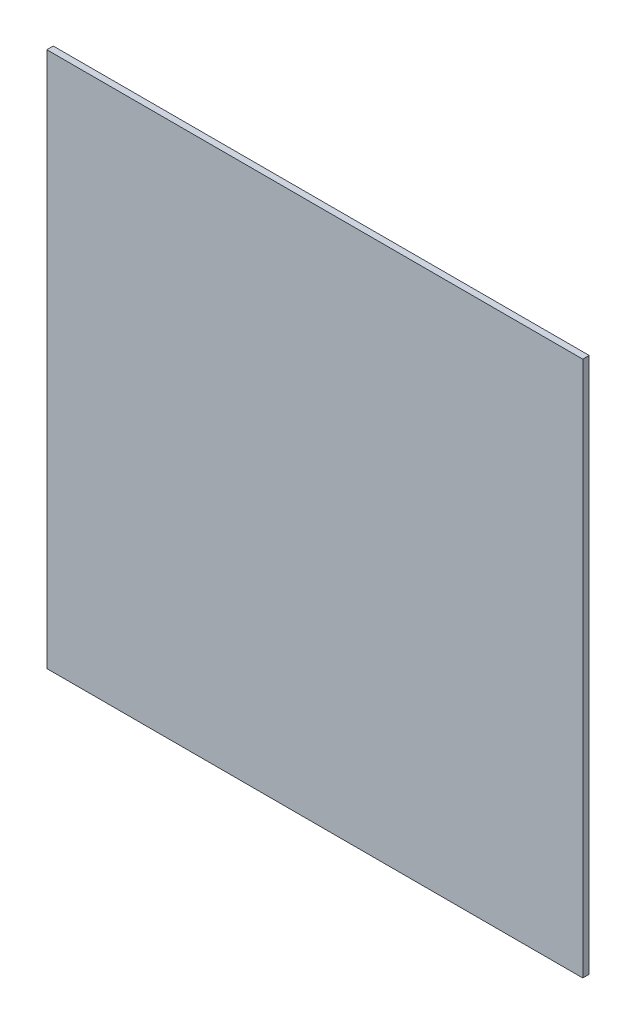
from build123d import *

# Parameters (mm, degrees)
SKETCH_1_W      = 250
SKETCH_1_H      = 3
EXTRUDE_1_DEPTH = 250


with BuildPart() as part:
    # 스케치1 → 보스-돌출1 (new body)
    with BuildSketch(Plane(origin=(0, 0, 0), x_dir=(1, 0, 0), z_dir=(0, 1, 0))):
        with Locations((125, 1.5)):
            Rectangle(SKETCH_1_W, SKETCH_1_H)
    extrude(amount=EXTRUDE_1_DEPTH)


solid = part.part
